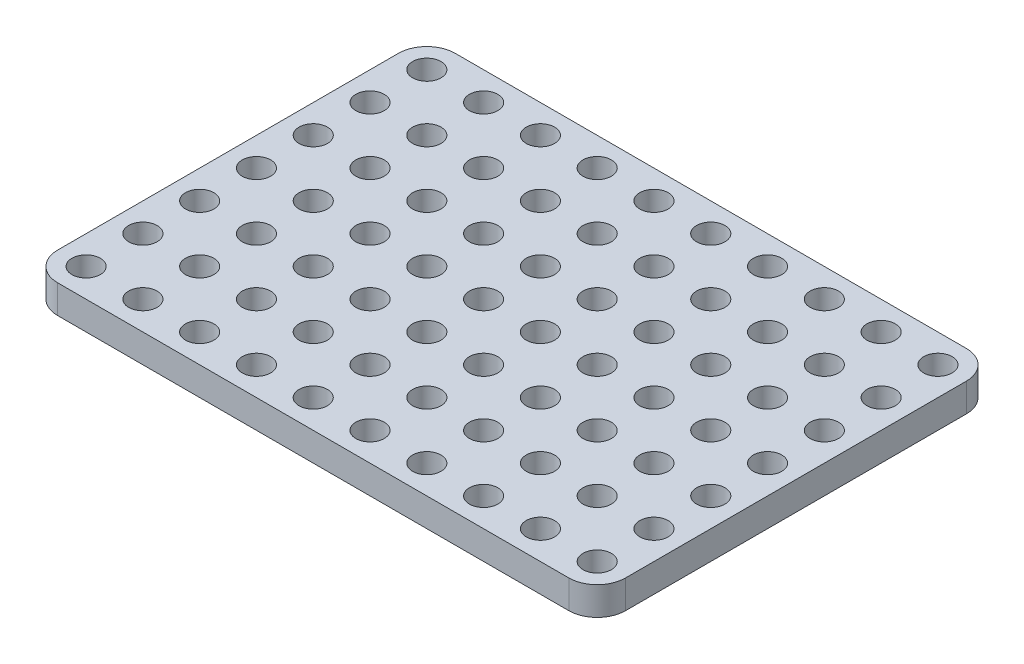
from build123d import *

# Parameters (mm, degrees)
SKETCH1_R           = 2.5
BOSS_EXTRUDE1_DEPTH = 5


with BuildPart() as part:
    # Sketch1 → Boss-Extrude1 (new body)
    with BuildSketch(Plane(origin=(0, 0, 0), x_dir=(1, 0, 0), z_dir=(0, 1, 0))):
        with BuildLine():
            Line((45, -35), (-45, -35))
            ThreePointArc((-45, -35), (-48.535533906, -33.535533906), (-50, -30))
            Line((-50, -30), (-50, 30))
            ThreePointArc((-50, 30), (-48.535533906, 33.535533906), (-45, 35))
            Line((-45, 35), (45, 35))
            ThreePointArc((45, 35), (48.535533906, 33.535533906), (50, 30))
            Line((50, 30), (50, -30))
            ThreePointArc((50, -30), (48.535533906, -33.535533906), (45, -35))
        make_face()
        with Locations((-45, 30)):
            Circle(SKETCH1_R, mode=Mode.SUBTRACT)
        with Locations((-35, 30)):
            Circle(SKETCH1_R, mode=Mode.SUBTRACT)
        with Locations((-25, 30)):
            Circle(SKETCH1_R, mode=Mode.SUBTRACT)
        with Locations((-15, 30)):
            Circle(SKETCH1_R, mode=Mode.SUBTRACT)
        with Locations((-5, 30)):
            Circle(SKETCH1_R, mode=Mode.SUBTRACT)
        with Locations((5, 30)):
            Circle(SKETCH1_R, mode=Mode.SUBTRACT)
        with Locations((15, 30)):
            Circle(SKETCH1_R, mode=Mode.SUBTRACT)
        with Locations((25, 30)):
            Circle(SKETCH1_R, mode=Mode.SUBTRACT)
        with Locations((35, 30)):
            Circle(SKETCH1_R, mode=Mode.SUBTRACT)
        with Locations((45, 30)):
            Circle(SKETCH1_R, mode=Mode.SUBTRACT)
        with Locations((-35, 20)):
            Circle(SKETCH1_R, mode=Mode.SUBTRACT)
        with Locations((-25, 20)):
            Circle(SKETCH1_R, mode=Mode.SUBTRACT)
        with Locations((-15, 20)):
            Circle(SKETCH1_R, mode=Mode.SUBTRACT)
        with Locations((-5, 20)):
            Circle(SKETCH1_R, mode=Mode.SUBTRACT)
        with Locations((5, 20)):
            Circle(SKETCH1_R, mode=Mode.SUBTRACT)
        with Locations((15, 20)):
            Circle(SKETCH1_R, mode=Mode.SUBTRACT)
        with Locations((25, 20)):
            Circle(SKETCH1_R, mode=Mode.SUBTRACT)
        with Locations((35, 20)):
            Circle(SKETCH1_R, mode=Mode.SUBTRACT)
        with Locations((45, 20)):
            Circle(SKETCH1_R, mode=Mode.SUBTRACT)
        with Locations((-35, 10)):
            Circle(SKETCH1_R, mode=Mode.SUBTRACT)
        with Locations((-25, 10)):
            Circle(SKETCH1_R, mode=Mode.SUBTRACT)
        with Locations((-15, 10)):
            Circle(SKETCH1_R, mode=Mode.SUBTRACT)
        with Locations((-5, 10)):
            Circle(SKETCH1_R, mode=Mode.SUBTRACT)
        with Locations((5, 10)):
            Circle(SKETCH1_R, mode=Mode.SUBTRACT)
        with Locations((15, 10)):
            Circle(SKETCH1_R, mode=Mode.SUBTRACT)
        with Locations((25, 10)):
            Circle(SKETCH1_R, mode=Mode.SUBTRACT)
        with Locations((35, 10)):
            Circle(SKETCH1_R, mode=Mode.SUBTRACT)
        with Locations((45, 10)):
            Circle(SKETCH1_R, mode=Mode.SUBTRACT)
        with Locations((-35, 0)):
            Circle(SKETCH1_R, mode=Mode.SUBTRACT)
        with Locations((-25, 0)):
            Circle(SKETCH1_R, mode=Mode.SUBTRACT)
        with Locations((-15, 0)):
            Circle(SKETCH1_R, mode=Mode.SUBTRACT)
        with Locations((-5, 0)):
            Circle(SKETCH1_R, mode=Mode.SUBTRACT)
        with Locations((5, 0)):
            Circle(SKETCH1_R, mode=Mode.SUBTRACT)
        with Locations((15, 0)):
            Circle(SKETCH1_R, mode=Mode.SUBTRACT)
        with Locations((25, 0)):
            Circle(SKETCH1_R, mode=Mode.SUBTRACT)
        with Locations((35, 0)):
            Circle(SKETCH1_R, mode=Mode.SUBTRACT)
        with Locations((45, 0)):
            Circle(SKETCH1_R, mode=Mode.SUBTRACT)
        with Locations((-35, -10)):
            Circle(SKETCH1_R, mode=Mode.SUBTRACT)
        with Locations((-25, -10)):
            Circle(SKETCH1_R, mode=Mode.SUBTRACT)
        with Locations((-15, -10)):
            Circle(SKETCH1_R, mode=Mode.SUBTRACT)
        with Locations((-5, -10)):
            Circle(SKETCH1_R, mode=Mode.SUBTRACT)
        with Locations((5, -10)):
            Circle(SKETCH1_R, mode=Mode.SUBTRACT)
        with Locations((15, -10)):
            Circle(SKETCH1_R, mode=Mode.SUBTRACT)
        with Locations((25, -10)):
            Circle(SKETCH1_R, mode=Mode.SUBTRACT)
        with Locations((35, -10)):
            Circle(SKETCH1_R, mode=Mode.SUBTRACT)
        with Locations((45, -10)):
            Circle(SKETCH1_R, mode=Mode.SUBTRACT)
        with Locations((-35, -20)):
            Circle(SKETCH1_R, mode=Mode.SUBTRACT)
        with Locations((-25, -20)):
            Circle(SKETCH1_R, mode=Mode.SUBTRACT)
        with Locations((-15, -20)):
            Circle(SKETCH1_R, mode=Mode.SUBTRACT)
        with Locations((-5, -20)):
            Circle(SKETCH1_R, mode=Mode.SUBTRACT)
        with Locations((5, -20)):
            Circle(SKETCH1_R, mode=Mode.SUBTRACT)
        with Locations((15, -20)):
            Circle(SKETCH1_R, mode=Mode.SUBTRACT)
        with Locations((25, -20)):
            Circle(SKETCH1_R, mode=Mode.SUBTRACT)
        with Locations((35, -20)):
            Circle(SKETCH1_R, mode=Mode.SUBTRACT)
        with Locations((45, -20)):
            Circle(SKETCH1_R, mode=Mode.SUBTRACT)
        with Locations((-35, -30)):
            Circle(SKETCH1_R, mode=Mode.SUBTRACT)
        with Locations((-25, -30)):
            Circle(SKETCH1_R, mode=Mode.SUBTRACT)
        with Locations((-15, -30)):
            Circle(SKETCH1_R, mode=Mode.SUBTRACT)
        with Locations((-5, -30)):
            Circle(SKETCH1_R, mode=Mode.SUBTRACT)
        with Locations((5, -30)):
            Circle(SKETCH1_R, mode=Mode.SUBTRACT)
        with Locations((15, -30)):
            Circle(SKETCH1_R, mode=Mode.SUBTRACT)
        with Locations((25, -30)):
            Circle(SKETCH1_R, mode=Mode.SUBTRACT)
        with Locations((35, -30)):
            Circle(SKETCH1_R, mode=Mode.SUBTRACT)
        with Locations((45, -30)):
            Circle(SKETCH1_R, mode=Mode.SUBTRACT)
        with Locations((-45, 20)):
            Circle(SKETCH1_R, mode=Mode.SUBTRACT)
        with Locations((-45, 10)):
            Circle(SKETCH1_R, mode=Mode.SUBTRACT)
        with Locations((-45, 0)):
            Circle(SKETCH1_R, mode=Mode.SUBTRACT)
        with Locations((-45, -10)):
            Circle(SKETCH1_R, mode=Mode.SUBTRACT)
        with Locations((-45, -20)):
            Circle(SKETCH1_R, mode=Mode.SUBTRACT)
        with Locations((-45, -30)):
            Circle(SKETCH1_R, mode=Mode.SUBTRACT)
    extrude(amount=BOSS_EXTRUDE1_DEPTH)


solid = part.part
